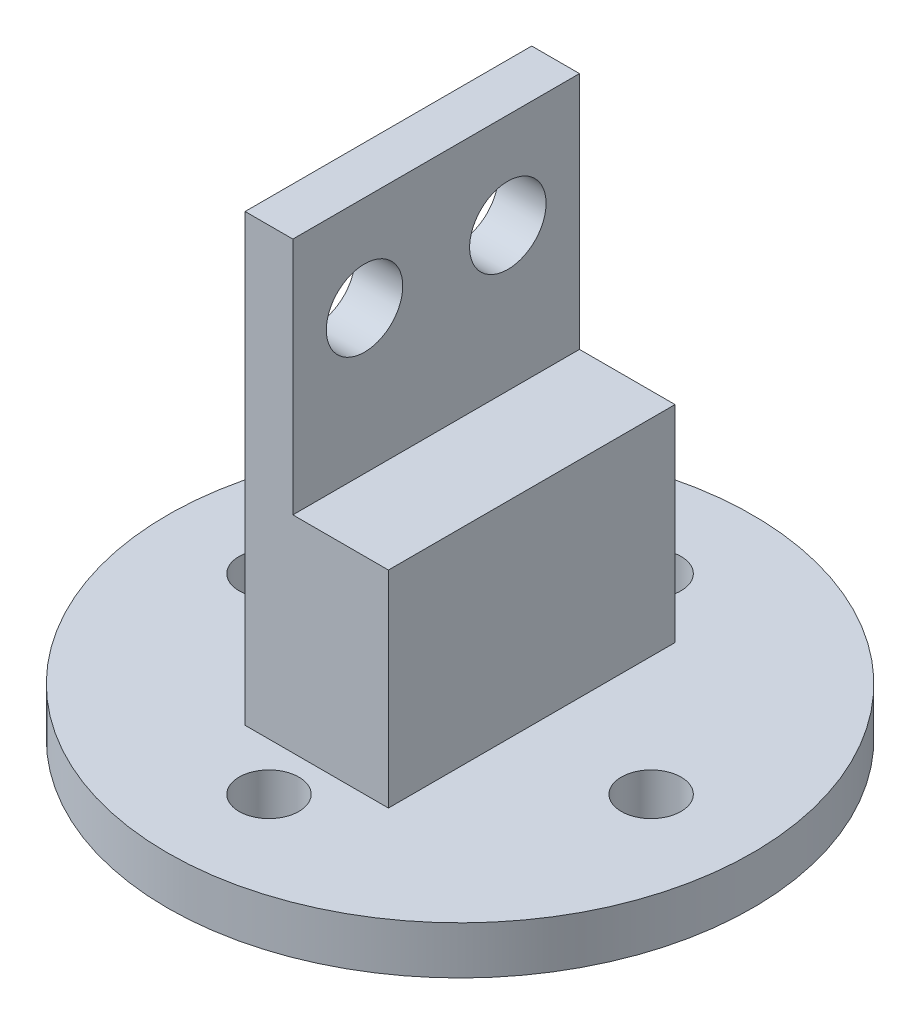
from build123d import *

# Parameters (mm, degrees)
SKETCH_1_R          = 12.25
SKETCH_1_R_2        = 1.25
EXTRUDE_1_DEPTH     = 2
SKETCH_2_R          = 3
EXTRUDE_2_DEPTH     = 10.63
SKETCH_3_W          = 2
SKETCH_3_H          = 12
EXTRUDE_3_DEPTH     = 8
SKETCH_5_R          = 1.6
CUT_EXTRUDE_1_DEPTH = 10
SKETCH_6_W          = 6
SKETCH_6_H          = 12
EXTRUDE_4_DEPTH     = 10.63
SKETCH_7_W          = 4
SKETCH_7_H          = 12
CUT_EXTRUDE_2_DEPTH = 2


with BuildPart() as part:
    # 草图1 → 凸台-拉伸1 (new body)
    with BuildSketch(Plane(origin=(0, 0, 0), x_dir=(1, 0, 0), z_dir=(0, 1, 0))):
        Circle(SKETCH_1_R)
        with Locations((8, 0)):
            Circle(SKETCH_1_R_2, mode=Mode.SUBTRACT)
        with Locations((0, -8)):
            Circle(SKETCH_1_R_2, mode=Mode.SUBTRACT)
        with Locations((-8, 0)):
            Circle(SKETCH_1_R_2, mode=Mode.SUBTRACT)
        with Locations((0, 8)):
            Circle(SKETCH_1_R_2, mode=Mode.SUBTRACT)
    extrude(amount=EXTRUDE_1_DEPTH)

    # 草图2 → 凸台-拉伸2 (add)
    with BuildSketch(Plane(origin=(0, 2, 0), x_dir=(1, 0, 0), z_dir=(0, 1, 0))):
        Circle(SKETCH_2_R)
    extrude(amount=EXTRUDE_2_DEPTH)

    # 草图3 → 凸台-拉伸3 (add)
    with BuildSketch(Plane(origin=(0, 12.63, 0), x_dir=(1, 0, 0), z_dir=(0, 1, 0))):
        with Locations((-2, 0)):
            Rectangle(SKETCH_3_W, SKETCH_3_H)
    extrude(amount=EXTRUDE_3_DEPTH)

    # 草图5 → 切除-拉伸1 (cut)
    with BuildSketch(Plane(origin=(-1, 0, 0), x_dir=(0, 0, -1), z_dir=(1, 0, 0))):
        with Locations((3, 16.63)):
            Circle(SKETCH_5_R)
        with Locations((-3, 16.63)):
            Circle(SKETCH_5_R)
    extrude(amount=-CUT_EXTRUDE_1_DEPTH, mode=Mode.SUBTRACT)

    # 草图6 → 凸台-拉伸4 (add)
    with BuildSketch(Plane(origin=(0, 2, 0), x_dir=(1, 0, 0), z_dir=(0, 1, 0))):
        Rectangle(SKETCH_6_W, SKETCH_6_H)
    extrude(amount=EXTRUDE_4_DEPTH)

    # 草图7 → 切除-拉伸2 (cut)
    with BuildSketch(Plane(origin=(0, 12.63, 0), x_dir=(1, 0, 0), z_dir=(0, 1, 0))):
        with Locations((1, 0)):
            Rectangle(SKETCH_7_W, SKETCH_7_H)
    extrude(amount=-CUT_EXTRUDE_2_DEPTH, mode=Mode.SUBTRACT)


solid = part.part
